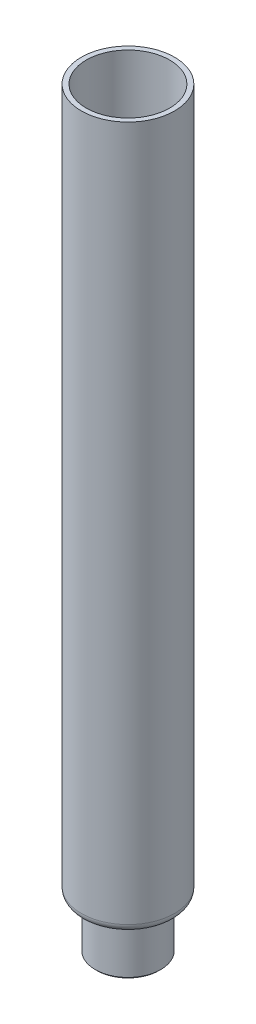
from build123d import *

# Parameters (mm, degrees)
CHANFREIN1_SIZE = 0.5


with BuildPart() as part:
    # Esquisse1 → Révolution1 (revolve)
    with BuildSketch(Plane.XY, mode=Mode.PRIVATE) as r_volution1_sk:
        with BuildLine():
            Line((8.5, -15), (8.5, -1))
            ThreePointArc((8.5, -1), (9.232233047, 0.767766953), (11, 1.5))
            Line((11, 1.5), (11.75, 1.5))
            ThreePointArc((11.75, 1.5), (12.457106781, 1.792893219), (12.75, 2.5))
            Line((12.75, 2.5), (12.75, 215))
            Line((12.75, 215), (14.25, 215))
            Line((14.25, 215), (14.25, 2.5))
            ThreePointArc((14.25, 2.5), (13.517766953, 0.732233047), (11.75, 0))
            Line((11.75, 0), (11, 0))
            ThreePointArc((11, 0), (10.292893219, -0.292893219), (10, -1))
            Line((10, -1), (10, -15))
            Line((10, -15), (8.5, -15))
        make_face()
    revolve(r_volution1_sk.sketch.rotate(Axis((0, 34.901303155, 0), (0, -1, 0)), 90), axis=Axis((0, 34.901303155, 0), (0, -1, 0)))  # turned: the seam where the file's is

    # Chanfrein1
    chanfrein1_edges = [part.edges().sort_by_distance(p)[0] for p in [
        (0, -15, -10),
    ]]
    chamfer(chanfrein1_edges, length=CHANFREIN1_SIZE)


solid = part.part
